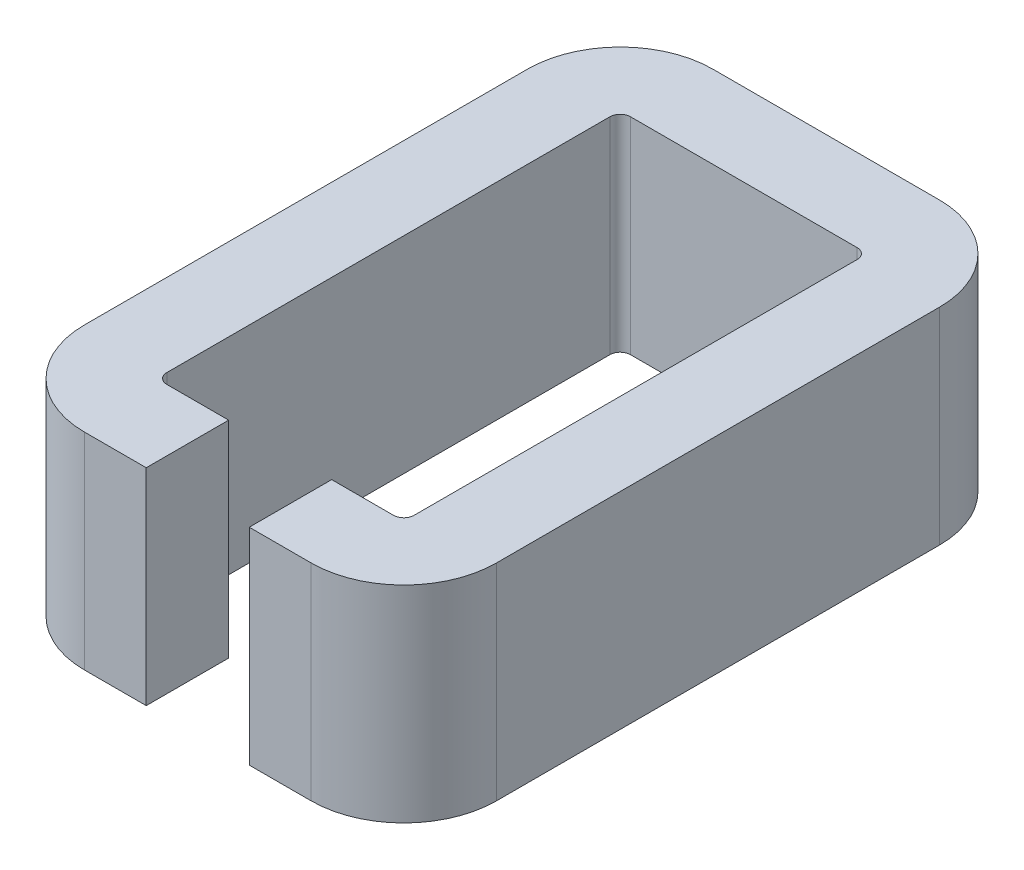
from build123d import *

# Parameters (mm, degrees)
BOSS_EXTRUDE1_DEPTH = 10


with BuildPart() as part:
    # Sketch1 → Boss-Extrude1 (new body)
    with BuildSketch(Plane(origin=(0, 0, 0), x_dir=(1, 0, 0), z_dir=(0, 1, 0))):
        with BuildLine():
            Line((-4, -0.5), (-4, -22))
            ThreePointArc((-4, -22), (-2.681980515, -25.181980515), (0.5, -26.5))
            Line((0.5, -26.5), (3.5, -26.5))
            Line((3.5, -26.5), (3.5, -22.5))
            Line((3.5, -22.5), (0.5, -22.5))
            ThreePointArc((0.5, -22.5), (0.146446609, -22.353553391), (0, -22))
            Line((0, -22), (0, -0.5))
            ThreePointArc((0, -0.5), (0.146446609, -0.146446609), (0.5, 0))
            Line((0.5, 0), (11.5, 0))
            ThreePointArc((11.5, 0), (11.853553391, -0.146446609), (12, -0.5))
            Line((12, -0.5), (12, -22))
            ThreePointArc((12, -22), (11.853553391, -22.353553391), (11.5, -22.5))
            Line((11.5, -22.5), (8.5, -22.5))
            Line((8.5, -22.5), (8.5, -26.5))
            Line((8.5, -26.5), (11.5, -26.5))
            ThreePointArc((11.5, -26.5), (14.681980515, -25.181980515), (16, -22))
            Line((16, -22), (16, -0.5))
            ThreePointArc((16, -0.5), (14.681980515, 2.681980515), (11.5, 4))
            Line((11.5, 4), (0.5, 4))
            ThreePointArc((0.5, 4), (-2.681980515, 2.681980515), (-4, -0.5))
        make_face()
    extrude(amount=BOSS_EXTRUDE1_DEPTH)


solid = part.part
